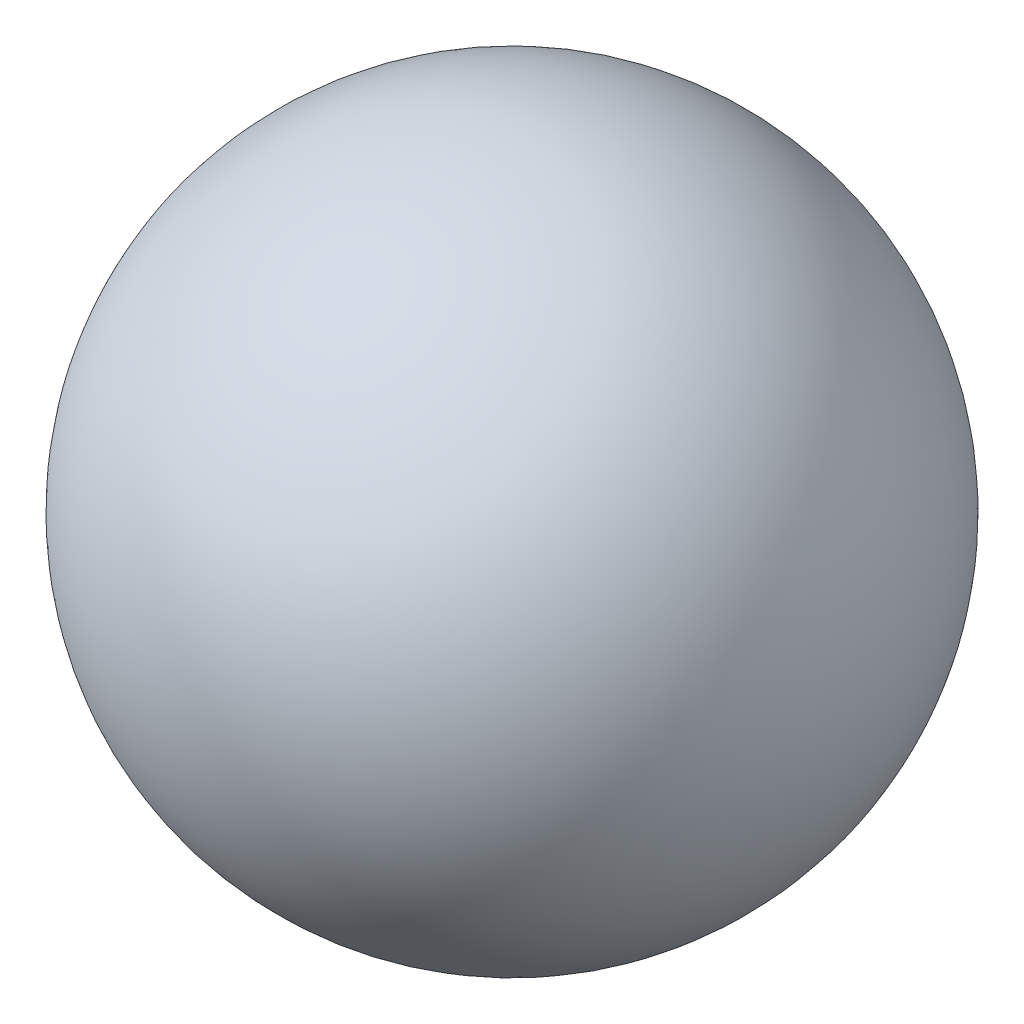
from build123d import *


with BuildPart() as part:
    # Sketch1 → Revolve1 (revolve)
    with BuildSketch(Plane(origin=(0, 0, 0), x_dir=(1, 0, 0), z_dir=(0, 1, 0))):
        with BuildLine():
            Line((-12.094488189, 0), (11.905511817, 0))
            ThreePointArc((11.905511817, 0), (-0.094488186, -12.000000003), (-12.094488189, 0))
        make_face()
    revolve(axis=Axis((-12.094488189, 0, 0), (1, 0, 0)))


solid = part.part
